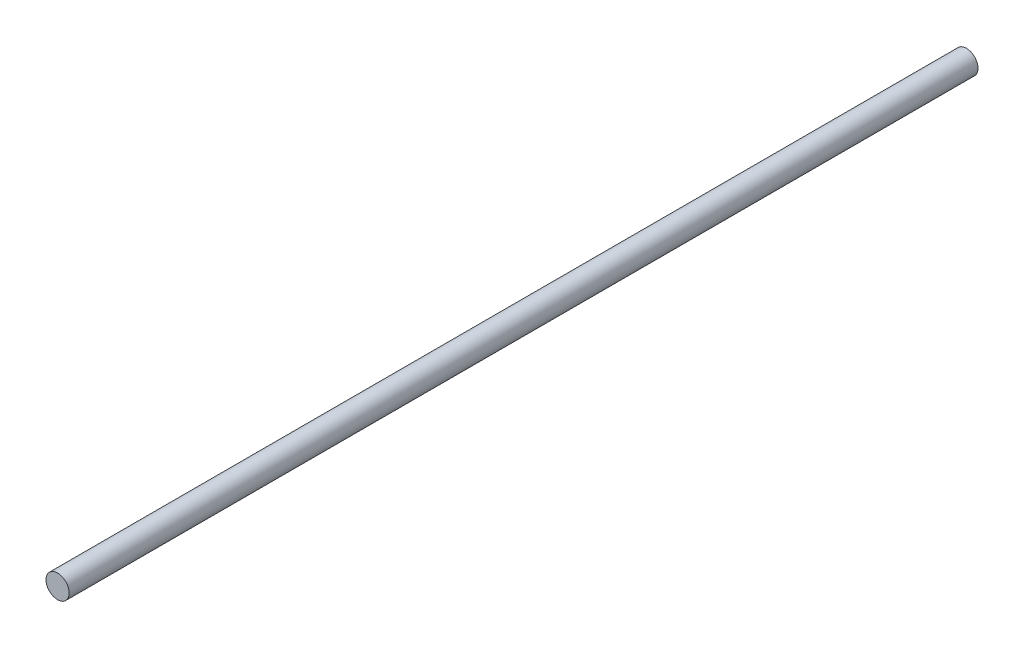
from build123d import *

# Parameters (mm, degrees)
SKETCH1_R           = 3.95
BOSS_EXTRUDE1_DEPTH = 310


with BuildPart() as part:
    # Sketch1 → Boss-Extrude1 (new body)
    with BuildSketch(Plane.XY):
        Circle(SKETCH1_R)
    extrude(amount=BOSS_EXTRUDE1_DEPTH)


solid = part.part
